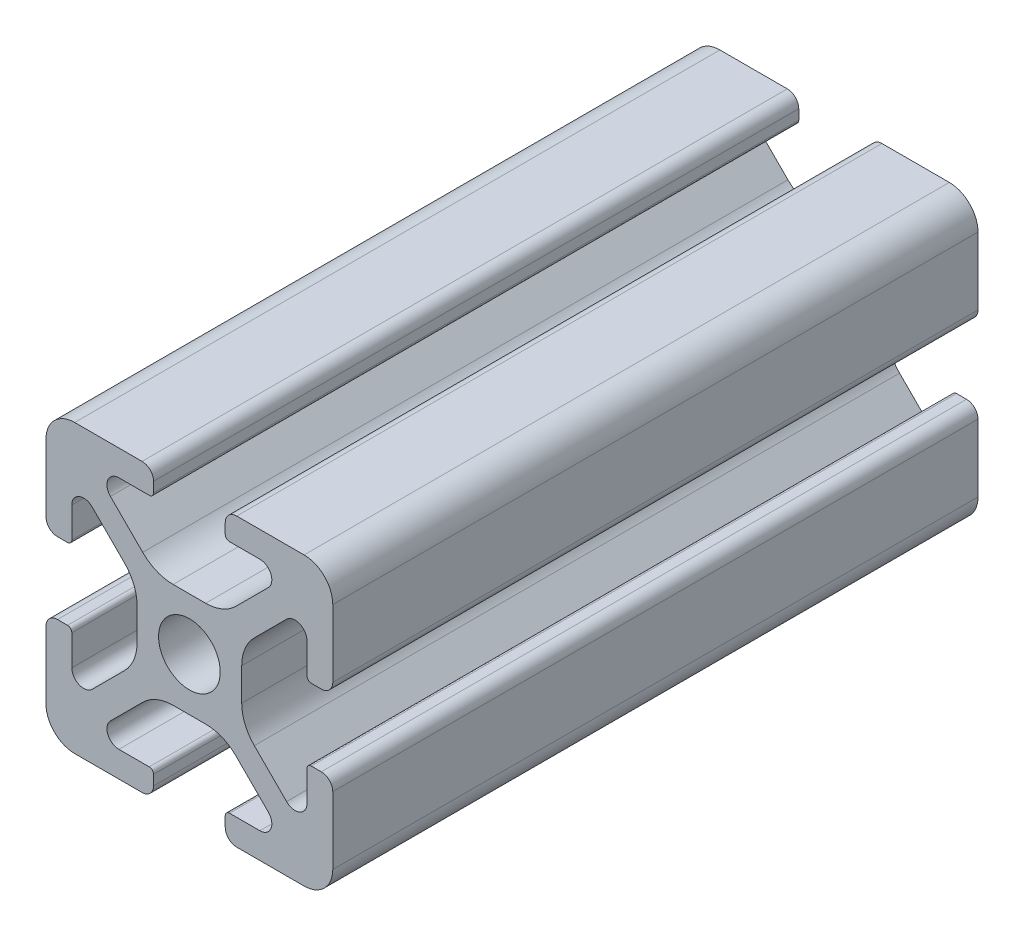
from build123d import *

# Parameters (mm, degrees)
SKETCH4_W              = 20
SKETCH4_H              = 20
BODY_DEPTH             = 45
SKETCH16_OUTSIDE_W     = 32.63
SKETCH16_OUTSIDE_H     = 32.63
SKETCH16_OUTSIDE_R     = 2.15
CUT_PROFILE_DEPTH      = 26
CUT_PROFILE_DEPTH_BACK = 21


with BuildPart() as part:
    # Sketch4 → Body (new body)
    with BuildSketch(Plane.XY.offset(25)):
        Rectangle(SKETCH4_W, SKETCH4_H)
    extrude(amount=-BODY_DEPTH)

    # Sketch16 outside → Cut-Profile (cut, two sides)
    with BuildSketch(Plane.XY) as cut_profile_sk:
        Rectangle(SKETCH16_OUTSIDE_W, SKETCH16_OUTSIDE_H)
        with BuildLine():
            Line((4.917588389, -8.199999991), (2.799999989, -8.199999991))
            ThreePointArc((2.799999989, -8.199999991), (2.587867955, -8.287867957), (2.499999989, -8.499999991))
            Line((2.499999989, -8.499999991), (2.499999989, -9.199999991))
            ThreePointArc((2.499999989, -9.199999991), (2.734314564, -9.765685416), (3.299999989, -9.999999991))
            Line((3.299999989, -9.999999991), (7.999999989, -9.999999991))
            ThreePointArc((7.999999989, -9.999999991), (9.414213552, -9.414213554), (9.999999989, -7.999999991))
            Line((9.999999989, -7.999999991), (9.999999989, -3.299999991))
            ThreePointArc((9.999999989, -3.299999991), (9.765685414, -2.734314566), (9.199999989, -2.499999991))
            Line((9.199999989, -2.499999991), (8.499999989, -2.499999991))
            ThreePointArc((8.499999989, -2.499999991), (8.287867955, -2.587867957), (8.199999989, -2.799999991))
            Line((8.199999989, -2.799999991), (8.199999989, -4.917588391))
            ThreePointArc((8.199999989, -4.917588391), (7.686138511, -5.686636441), (6.778984485, -5.506192286))
            Line((6.778984485, -5.506192286), (4.528679645, -3.255887446))
            ThreePointArc((4.528679645, -3.255887446), (3.878361392, -2.282617401), (3.64999999, -1.134567106))
            Line((3.64999999, -1.134567106), (3.64999999, 1.134567104))
            ThreePointArc((3.64999999, 1.134567104), (3.878361393, 2.282617402), (4.528679647, 3.255887448))
            Line((4.528679647, 3.255887448), (6.778984487, 5.506192288))
            ThreePointArc((6.778984487, 5.506192288), (7.686138506, 5.686636442), (8.199999981, 4.917588398))
            Line((8.199999981, 4.917588398), (8.199999981, 2.799999998))
            ThreePointArc((8.199999981, 2.799999998), (8.287867946, 2.587867964), (8.499999981, 2.499999998))
            Line((8.499999981, 2.499999998), (9.199999981, 2.499999998))
            ThreePointArc((9.199999981, 2.499999998), (9.765685406, 2.734314573), (9.999999981, 3.299999998))
            Line((9.999999981, 3.299999998), (9.999999981, 7.999999998))
            ThreePointArc((9.999999981, 7.999999998), (9.414213543, 9.41421356), (7.999999981, 9.999999998))
            Line((7.999999981, 9.999999998), (3.299999981, 9.999999998))
            ThreePointArc((3.299999981, 9.999999998), (2.734314556, 9.765685423), (2.499999981, 9.199999998))
            Line((2.499999981, 9.199999998), (2.499999981, 8.499999998))
            ThreePointArc((2.499999981, 8.499999998), (2.587867946, 8.287867964), (2.799999981, 8.199999998))
            Line((2.799999981, 8.199999998), (4.917588381, 8.199999998))
            ThreePointArc((4.917588381, 8.199999998), (5.68663643, 7.68613852), (5.506192275, 6.778984494))
            Line((5.506192275, 6.778984494), (3.255887435, 4.528679654))
            ThreePointArc((3.255887435, 4.528679654), (2.28261739, 3.878361401), (1.134567095, 3.649999999))
            Line((1.134567095, 3.649999999), (-1.134567115, 3.649999999))
            ThreePointArc((-1.134567115, 3.649999999), (-2.282617412, 3.878361401), (-3.255887459, 4.528679655))
            Line((-3.255887459, 4.528679655), (-5.506192299, 6.778984495))
            ThreePointArc((-5.506192299, 6.778984495), (-5.686636452, 7.686138515), (-4.917588409, 8.199999989))
            Line((-4.917588409, 8.199999989), (-2.800000009, 8.199999989))
            ThreePointArc((-2.800000009, 8.199999989), (-2.587867974, 8.287867955), (-2.500000009, 8.499999989))
            Line((-2.500000009, 8.499999989), (-2.500000009, 9.199999989))
            ThreePointArc((-2.500000009, 9.199999989), (-2.734314584, 9.765685414), (-3.300000009, 9.999999989))
            Line((-3.300000009, 9.999999989), (-8.000000009, 9.999999989))
            ThreePointArc((-8.000000009, 9.999999989), (-9.414213571, 9.414213552), (-10.000000009, 7.999999989))
            Line((-10.000000009, 7.999999989), (-10.000000009, 3.299999989))
            ThreePointArc((-10.000000009, 3.299999989), (-9.765685434, 2.734314564), (-9.200000009, 2.499999989))
            Line((-9.200000009, 2.499999989), (-8.500000009, 2.499999989))
            ThreePointArc((-8.500000009, 2.499999989), (-8.287867974, 2.587867955), (-8.200000009, 2.799999989))
            Line((-8.200000009, 2.799999989), (-8.200000009, 4.917588389))
            ThreePointArc((-8.200000009, 4.917588389), (-7.686138531, 5.686636438), (-6.778984504, 5.506192284))
            Line((-6.778984504, 5.506192284), (-4.528679664, 3.255887444))
            ThreePointArc((-4.528679664, 3.255887444), (-3.878361412, 2.282617399), (-3.650000009, 1.134567104))
            Line((-3.650000009, 1.134567104), (-3.650000009, -1.134567106))
            ThreePointArc((-3.650000009, -1.134567106), (-3.878361412, -2.282617404), (-4.528679666, -3.25588745))
            Line((-4.528679666, -3.25588745), (-6.778984506, -5.50619229))
            ThreePointArc((-6.778984506, -5.50619229), (-7.686138526, -5.686636444), (-8.2, -4.9175884))
            Line((-8.2, -4.9175884), (-8.2, -2.8))
            ThreePointArc((-8.2, -2.8), (-8.287867966, -2.587867966), (-8.5, -2.5))
            Line((-8.5, -2.5), (-9.2, -2.5))
            ThreePointArc((-9.2, -2.5), (-9.765685425, -2.734314575), (-10, -3.3))
            Line((-10, -3.3), (-10, -8))
            ThreePointArc((-10, -8), (-9.414213562, -9.414213562), (-8, -10))
            Line((-8, -10), (-3.3, -10))
            ThreePointArc((-3.3, -10), (-2.734314575, -9.765685425), (-2.5, -9.2))
            Line((-2.5, -9.2), (-2.5, -8.5))
            ThreePointArc((-2.5, -8.5), (-2.587867966, -8.287867966), (-2.8, -8.2))
            Line((-2.8, -8.2), (-4.9175884, -8.2))
            ThreePointArc((-4.9175884, -8.2), (-5.686636449, -7.686138522), (-5.506192294, -6.778984496))
            Line((-5.506192294, -6.778984496), (-3.255887454, -4.528679656))
            ThreePointArc((-3.255887454, -4.528679656), (-2.282617409, -3.878361403), (-1.134567114, -3.650000001))
            Line((-1.134567114, -3.650000001), (1.134567096, -3.650000001))
            ThreePointArc((1.134567096, -3.650000001), (2.282617393, -3.878361403), (3.255887439, -4.528679657))
            Line((3.255887439, -4.528679657), (5.506192279, -6.778984497))
            ThreePointArc((5.506192279, -6.778984497), (5.686636433, -7.686138517), (4.917588389, -8.199999991))
        make_face(mode=Mode.SUBTRACT)
        Circle(SKETCH16_OUTSIDE_R)
    extrude(amount=CUT_PROFILE_DEPTH, mode=Mode.SUBTRACT)
    extrude(cut_profile_sk.sketch, amount=-CUT_PROFILE_DEPTH_BACK, mode=Mode.SUBTRACT)


solid = part.part
